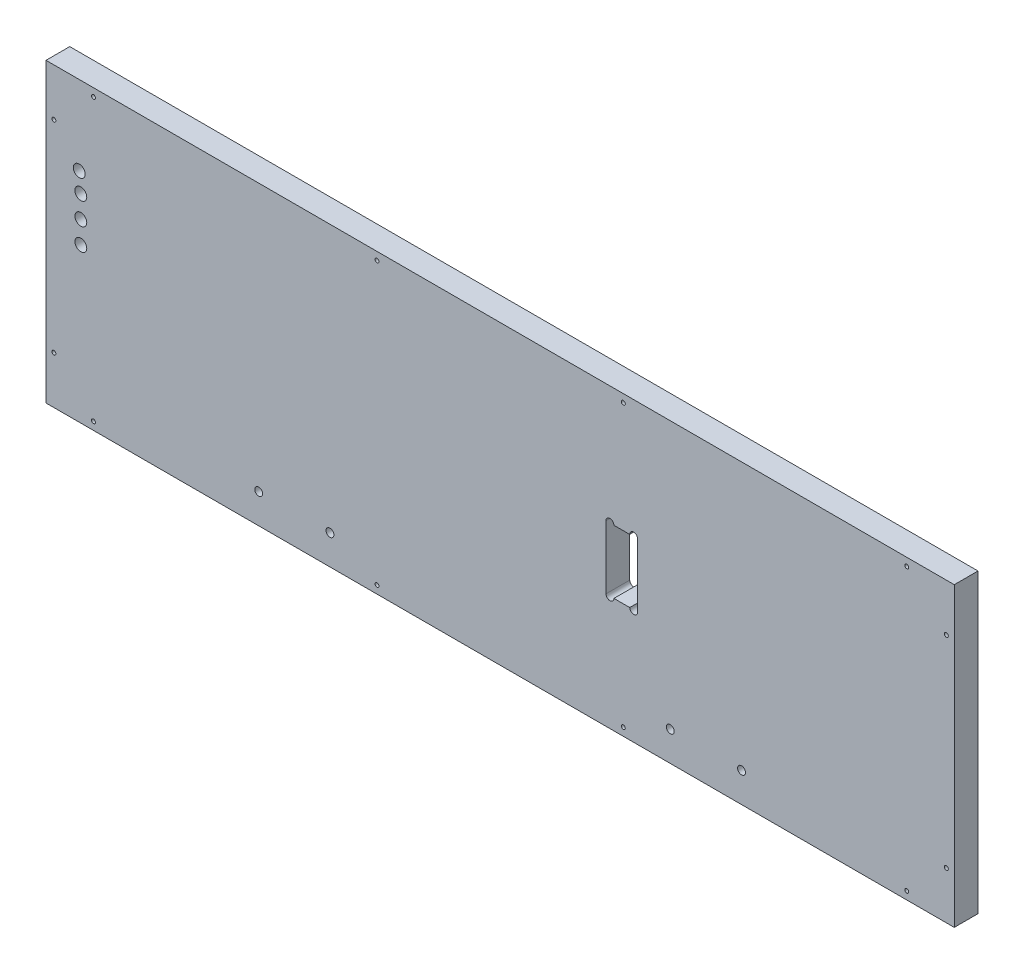
from build123d import *

# Parameters (mm, degrees)
SKETCH2_W          = 728.6625
SKETCH2_H          = 238.125
EXTRUDE1_DEPTH     = 19.05
SKETCH3_R          = 1.5875
SKETCH3_R_2        = 4.7625
SKETCH3_R_3        = 3.175
CUT_EXTRUDE1_DEPTH = 19.05
SKETCH4_W          = 169.8625
SKETCH4_H          = 9.525
CUT_EXTRUDE2_DEPTH = 3.175


with BuildPart() as part:
    # Sketch2 → Extrude1 (new body)
    with BuildSketch(Plane.XY):
        with Locations((-5376.06875, 779.4625)):
            Rectangle(SKETCH2_W, SKETCH2_H)
    extrude(amount=-EXTRUDE1_DEPTH)

    # Sketch3 → Cut-Extrude1 (cut)
    with BuildSketch(Plane.XY):
        with Locations((-5702.3, 892.175)):
            Circle(SKETCH3_R)
        with Locations((-5734.05, 860.425)):
            Circle(SKETCH3_R)
        with Locations((-5713.73, 835.025)):
            Circle(SKETCH3_R_2)
        with Locations((-5712.46, 819.785)):
            Circle(SKETCH3_R_2)
        with Locations((-5712.46, 802.005)):
            Circle(SKETCH3_R_2)
        with Locations((-5712.46, 784.225)):
            Circle(SKETCH3_R_2)
        with Locations((-5734.05, 698.5)):
            Circle(SKETCH3_R)
        with Locations((-5702.3, 666.75)):
            Circle(SKETCH3_R)
        with Locations((-5569.74375, 684.2125)):
            Circle(SKETCH3_R_3)
        with Locations((-5512.59375, 684.2125)):
            Circle(SKETCH3_R_3)
        with Locations((-5474.890625, 666.75)):
            Circle(SKETCH3_R)
        with Locations((-5277.246875, 666.75)):
            Circle(SKETCH3_R)
        with Locations((-5239.54375, 684.2125)):
            Circle(SKETCH3_R_3)
        with Locations((-5182.39375, 684.2125)):
            Circle(SKETCH3_R_3)
        with Locations((-5049.8375, 666.75)):
            Circle(SKETCH3_R)
        with Locations((-5018.0875, 698.5)):
            Circle(SKETCH3_R)
        with Locations((-5018.0875, 860.425)):
            Circle(SKETCH3_R)
        with Locations((-5049.8375, 892.175)):
            Circle(SKETCH3_R)
        with Locations((-5277.246875, 892.175)):
            Circle(SKETCH3_R)
        with Locations((-5474.890625, 892.175)):
            Circle(SKETCH3_R)
        with BuildLine():
            Line((-5291.1375, 803.275), (-5291.1375, 752.475))
            ThreePointArc((-5291.1375, 752.475), (-5287.9625, 749.3), (-5284.7875, 752.475))
            Line((-5284.7875, 752.475), (-5272.0875, 752.475))
            ThreePointArc((-5272.0875, 752.475), (-5268.9125, 749.3), (-5265.7375, 752.475))
            Line((-5265.7375, 752.475), (-5265.7375, 803.275))
            ThreePointArc((-5265.7375, 803.275), (-5268.9125, 806.45), (-5272.0875, 803.275))
            Line((-5272.0875, 803.275), (-5284.7875, 803.275))
            ThreePointArc((-5284.7875, 803.275), (-5287.9625, 806.45), (-5291.1375, 803.275))
        make_face()
    extrude(amount=-CUT_EXTRUDE1_DEPTH, mode=Mode.SUBTRACT)

    # Sketch4 → Cut-Extrude2 (cut)
    with BuildSketch(Plane.XZ.offset(-660.4)):
        with Locations((-5376.06875, -14.2875)):
            Rectangle(SKETCH4_W, SKETCH4_H)
    extrude(amount=-CUT_EXTRUDE2_DEPTH, mode=Mode.SUBTRACT)


solid = part.part
